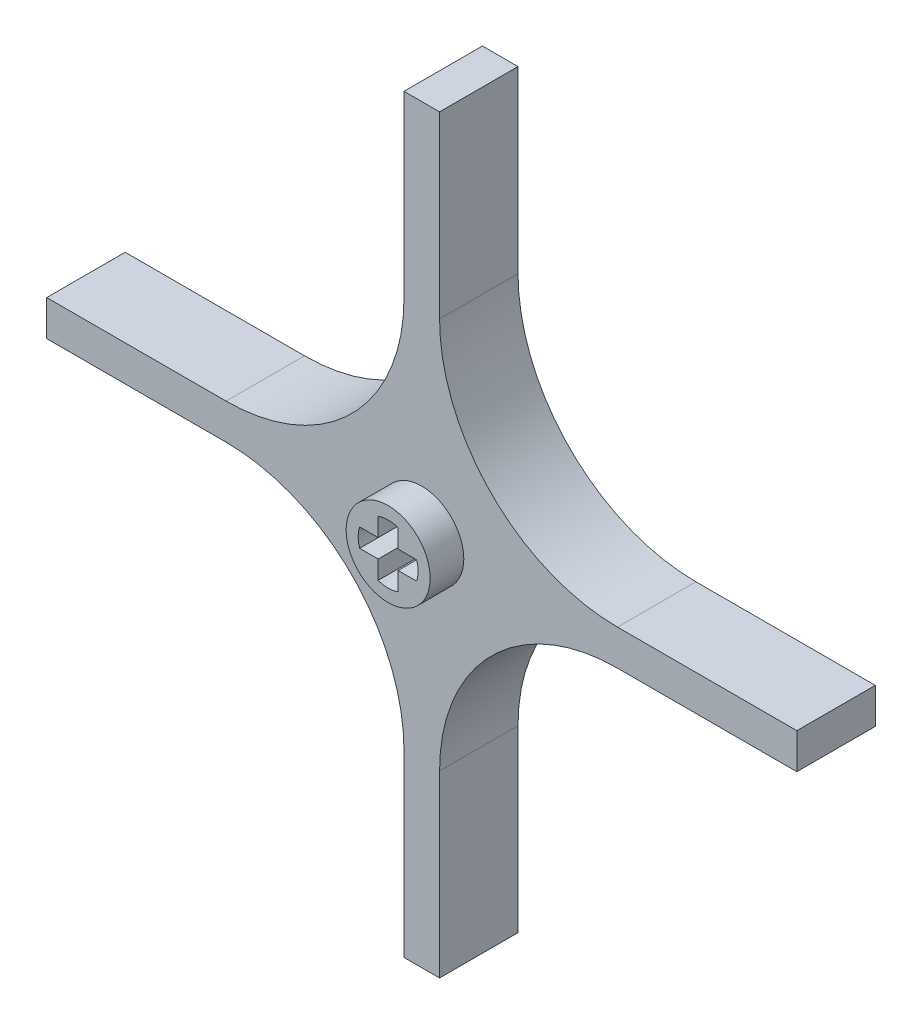
from build123d import *

# Parameters (mm, degrees)
BOSS_EXTRUDE1_DEPTH      = 3.5
FILLET1_R                = 15.875
SKETCH3_R                = 3.75
BOSS_EXTRUDE2_DEPTH      = 3
BOSS_EXTRUDE2_DEPTH_BACK = 9.99999997
CUT_EXTRUDE1_DEPTH       = 13.99999997


with BuildPart() as part:
    # Sketch1 → Boss-Extrude1 (new body, symmetric)
    with BuildSketch(Plane.XY):
        Polygon((1.5875, -1.5875), (1.5875, -33.4645), (-1.5875, -33.4645), (-1.5875, -1.5875), (-33.4645, -1.5875), (-33.4645, 1.5875), (-1.5875, 1.5875), (-1.5875, 33.4645), (1.5875, 33.4645), (1.5875, 1.5875), (33.4645, 1.5875), (33.4645, -1.5875), align=None)
    extrude(amount=BOSS_EXTRUDE1_DEPTH, both=True)

    # Fillet1
    fillet1_edges = [part.edges().sort_by_distance(p)[0] for p in [
        (-1.5875, 1.5875, 0),
        (1.5875, 1.5875, 0),
        (1.5875, -1.5875, 0),
        (-1.5875, -1.5875, 0),
    ]]
    fillet(fillet1_edges, radius=FILLET1_R)

    # Sketch3 → Boss-Extrude2 (add, two sides)
    with BuildSketch(Plane(origin=(0, 0, -3.5), x_dir=(-1, 0, 0), z_dir=(0, 0, -1))) as boss_extrude2_sk:
        Circle(SKETCH3_R)
    extrude(amount=BOSS_EXTRUDE2_DEPTH)
    extrude(boss_extrude2_sk.sketch, amount=-BOSS_EXTRUDE2_DEPTH_BACK)

    # Sketch4 → Cut-Extrude1 (cut, through all)
    with BuildSketch(Plane(origin=(0, 0, -6.5), x_dir=(-1, 0, 0), z_dir=(0, 0, -1))):
        with BuildLine():
            Line((-0.889, 0.8255), (-0.889, 2.4765))
            ThreePointArc((-0.889, 2.4765), (0, 2.633207345), (0.889, 2.4765))
            Line((0.889, 2.4765), (0.889, 0.8255))
            Line((0.889, 0.8255), (2.54, 0.8255))
            ThreePointArc((2.54, 0.8255), (2.674528493, 0), (2.54, -0.8255))
            Line((2.54, -0.8255), (0.889, -0.8255))
            Line((0.889, -0.8255), (0.889, -2.4765))
            ThreePointArc((0.889, -2.4765), (0, -2.633207345), (-0.889, -2.4765))
            Line((-0.889, -2.4765), (-0.889, -0.8255))
            Line((-0.889, -0.8255), (-2.54, -0.8255))
            ThreePointArc((-2.54, -0.8255), (-2.674528493, 0), (-2.54, 0.8255))
            Line((-2.54, 0.8255), (-0.889, 0.8255))
        make_face()
    extrude(amount=-CUT_EXTRUDE1_DEPTH, mode=Mode.SUBTRACT)


solid = part.part
